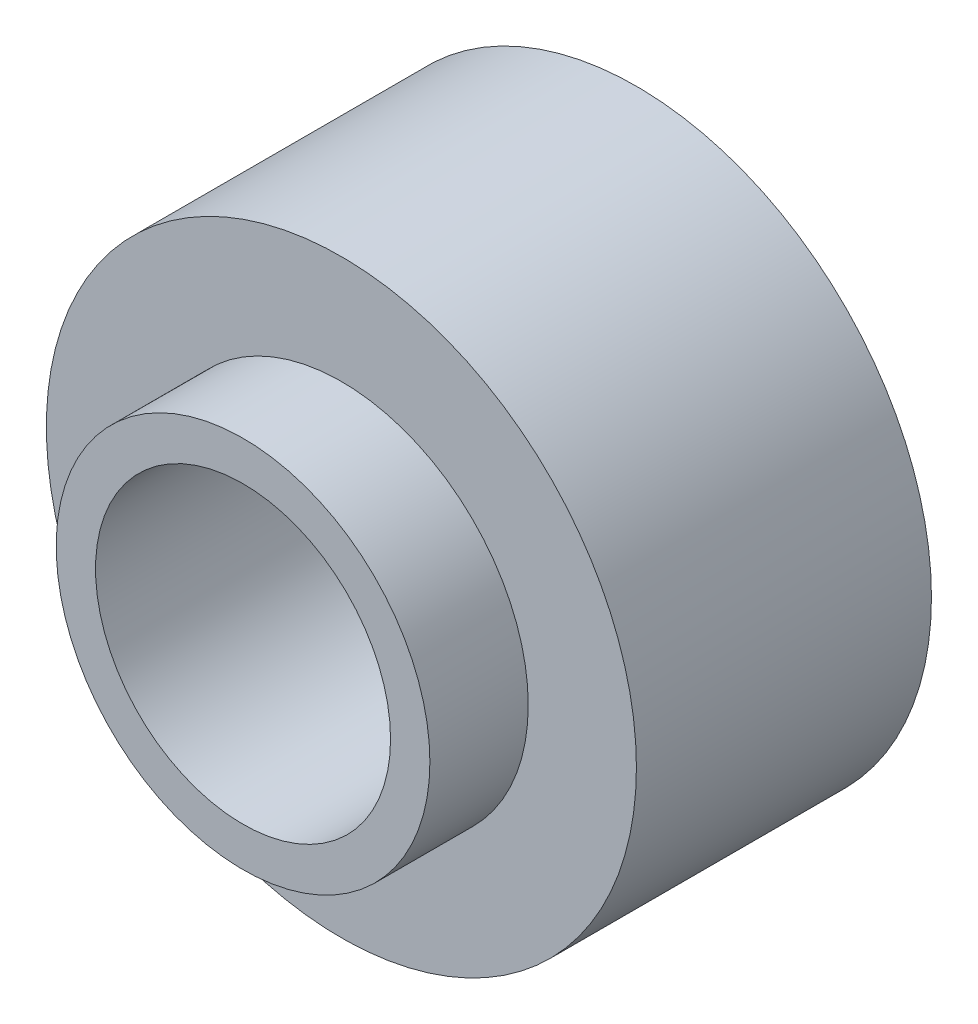
from build123d import *

# Parameters (mm, degrees)
SKETCH2_R           = 9.525
SKETCH2_R_2         = 4.7625
BOSS_EXTRUDE1_DEPTH = 12.7
SKETCH3_R           = 9.525
SKETCH3_R_2         = 6.0325
CUT_EXTRUDE1_DEPTH  = 3.175


with BuildPart() as part:
    # Sketch2 → Boss-Extrude1 (new body)
    with BuildSketch(Plane.XY):
        Circle(SKETCH2_R)
        Circle(SKETCH2_R_2, mode=Mode.SUBTRACT)
    extrude(amount=BOSS_EXTRUDE1_DEPTH)

    # Sketch3 → Cut-Extrude1 (cut)
    with BuildSketch(Plane.XY.offset(12.7)):
        Circle(SKETCH3_R)
        Circle(SKETCH3_R_2, mode=Mode.SUBTRACT)
    extrude(amount=-CUT_EXTRUDE1_DEPTH, mode=Mode.SUBTRACT)


solid = part.part
